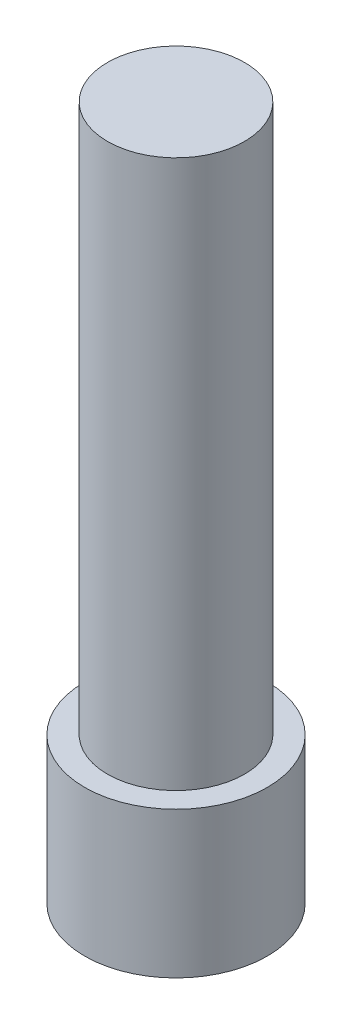
from build123d import *

# Parameters (mm, degrees)
SKETCH1_R           = 37.5
BOSS_EXTRUDE1_DEPTH = 300
SKETCH2_R           = 50
BOSS_EXTRUDE2_DEPTH = 80


with BuildPart() as part:
    # Sketch1 → Boss-Extrude1 (new body)
    with BuildSketch(Plane(origin=(0, 0, 0), x_dir=(1, 0, 0), z_dir=(0, 1, 0))):
        Circle(SKETCH1_R)
    extrude(amount=BOSS_EXTRUDE1_DEPTH)

    # Sketch2 → Boss-Extrude2 (add)
    with BuildSketch(Plane(origin=(0, 0, 0), x_dir=(1, 0, 0), z_dir=(0, 1, 0))):
        Circle(SKETCH2_R)
    extrude(amount=-BOSS_EXTRUDE2_DEPTH)


solid = part.part
